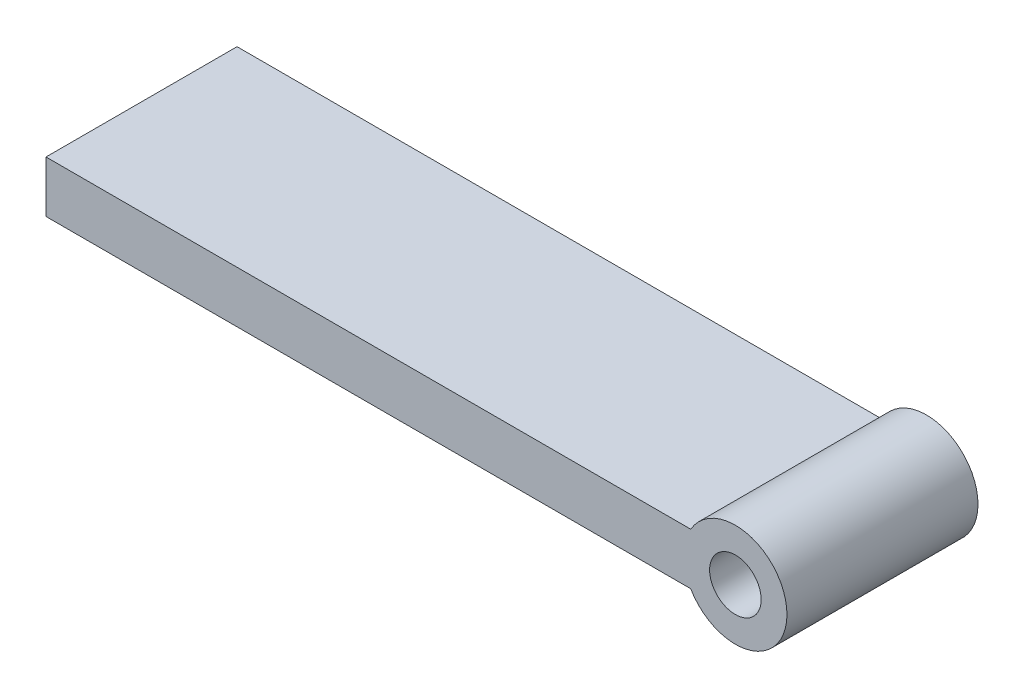
from build123d import *

# Parameters (mm, degrees)
SKETCH1_R           = 3
BOSS_EXTRUDE1_DEPTH = 22.225


with BuildPart() as part:
    # Sketch1 → Boss-Extrude1 (new body)
    with BuildSketch(Plane.XY):
        with BuildLine():
            Line((0, 0), (0, 6))
            Line((0, 6), (75.003847577, 6))
            ThreePointArc((75.003847577, 6), (86.2, 3), (75.003847577, 0))
            Line((75.003847577, 0), (0, 0))
        make_face()
        with Locations((80.2, 3)):
            Circle(SKETCH1_R, mode=Mode.SUBTRACT)
    extrude(amount=BOSS_EXTRUDE1_DEPTH)


solid = part.part
